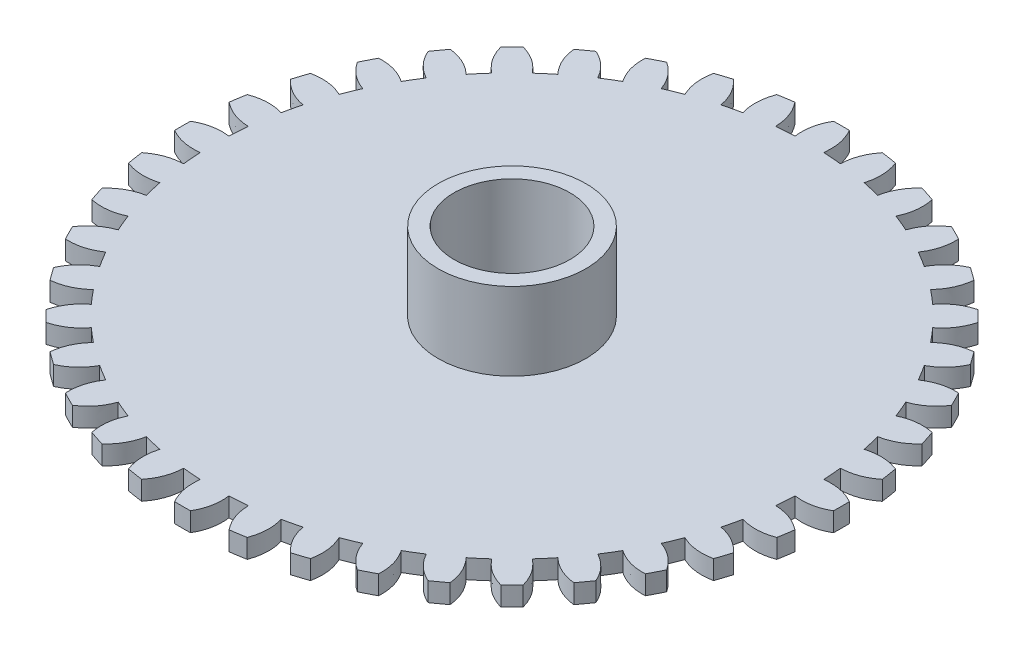
from build123d import *

# Parameters (mm, degrees)
SKETCH2_R           = 3.75
BOSS_EXTRUDE1_DEPTH = 0.24
BOSS_EXTRUDE2_DEPTH = 0.24
CIRPATTERN1_COUNT   = 40
SKETCH3_R           = 0.93
BOSS_EXTRUDE3_DEPTH = 0.98
SKETCH4_R           = 0.73
CUT_EXTRUDE1_DEPTH  = 2.2200001


with BuildPart() as part:
    # Sketch2 → Boss-Extrude1 (new body)
    with BuildSketch(Plane(origin=(0, 0, 0), x_dir=(1, 0, 0), z_dir=(0, 1, 0))):
        Circle(SKETCH2_R)
    extrude(amount=BOSS_EXTRUDE1_DEPTH)

    # Sketch1 → Boss-Extrude2 (add)
    with BuildSketch(Plane(origin=(0, 0, 0), x_dir=(1, 0, 0), z_dir=(0, 1, 0))):
        with BuildLine():
            ThreePointArc((-0.1, -4.148795006), (0, -4.15), (0.1, -4.148795006))
            add(Edge.make_bspline(
                [(0.18, -3.745677509), (0.207634944, -3.960090672), (0.1, -4.148795006)],
                knots=[0, 0, 0, 1, 1, 1], degree=2))
            ThreePointArc((0.18, -3.745677509), (0, -3.75), (-0.18, -3.745677509))
            add(Edge.make_bspline(
                [(-0.18, -3.745677509), (-0.207634944, -3.960090672), (-0.1, -4.148795006)],
                knots=[0, 0, 0, 1, 1, 1], degree=2))
        make_face()
    boss_extrude2 = extrude(amount=BOSS_EXTRUDE2_DEPTH)

    # CirPattern1: Boss-Extrude2 ×40 about axis
    cirpattern1_axis = Axis((0, 0.24, 0), (0, -1, 0))
    for i in range(1, CIRPATTERN1_COUNT):
        add(boss_extrude2.rotate(cirpattern1_axis, i * 360 / CIRPATTERN1_COUNT))

    # Sketch3 → Boss-Extrude3 (add)
    with BuildSketch(Plane(origin=(0, 0.24, 0), x_dir=(1, 0, 0), z_dir=(0, 1, 0))):
        Circle(SKETCH3_R)
    extrude(amount=BOSS_EXTRUDE3_DEPTH)

    # Sketch4 → Cut-Extrude1 (cut, through all)
    with BuildSketch(Plane(origin=(0, 1.22, 0), x_dir=(1, 0, 0), z_dir=(0, 1, 0))):
        Circle(SKETCH4_R)
    extrude(amount=-CUT_EXTRUDE1_DEPTH, mode=Mode.SUBTRACT)


solid = part.part
